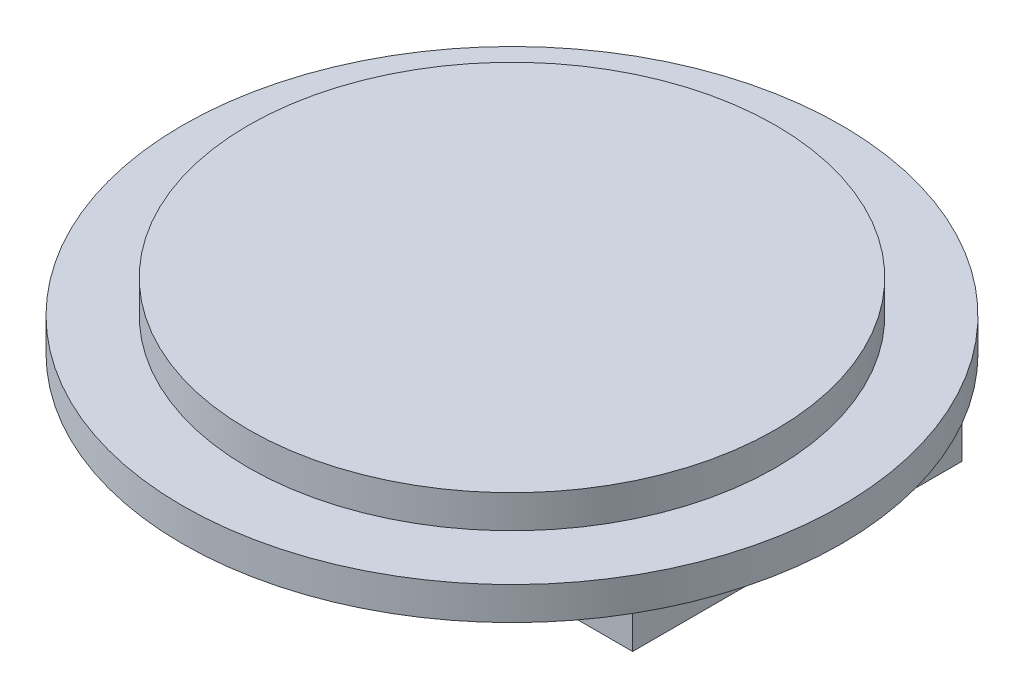
from build123d import *

# Parameters (mm, degrees)
ESBO_O1_R                = 10
RESSALTO_EXTRUS_O1_DEPTH = 1
ESBO_O2_R                = 8
RESSALTO_EXTRUS_O2_DEPTH = 1
ESBO_O3_W                = 17.320508076
ESBO_O3_H                = 10
RESSALTO_EXTRUS_O3_DEPTH = 1


with BuildPart() as part:
    # Esboço1 → Ressalto-extrusão1 (new body)
    with BuildSketch(Plane(origin=(0, 0, 0), x_dir=(1, 0, 0), z_dir=(0, 1, 0))):
        Circle(ESBO_O1_R)
    extrude(amount=RESSALTO_EXTRUS_O1_DEPTH)

    # Esboço2 → Ressalto-extrusão2 (add)
    with BuildSketch(Plane(origin=(0, 1, 0), x_dir=(1, 0, 0), z_dir=(0, 1, 0))):
        Circle(ESBO_O2_R)
    extrude(amount=RESSALTO_EXTRUS_O2_DEPTH)

    # Esboço3 → Ressalto-extrusão3 (add)
    with BuildSketch(Plane.XZ):
        Rectangle(ESBO_O3_W, ESBO_O3_H)
    extrude(amount=RESSALTO_EXTRUS_O3_DEPTH)


solid = part.part
